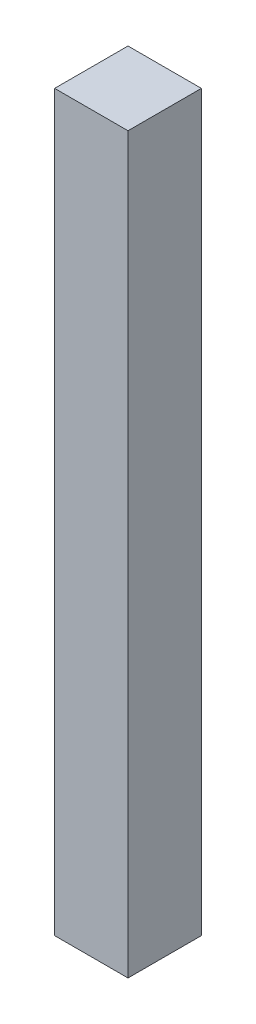
from build123d import *

# Parameters (mm, degrees)
SKETCH1_W           = 10
SKETCH1_H           = 100
BOSS_EXTRUDE1_DEPTH = 10


with BuildPart() as part:
    # Sketch1 → Boss-Extrude1 (new body)
    with BuildSketch(Plane.XY):
        Rectangle(SKETCH1_W, SKETCH1_H)
    extrude(amount=BOSS_EXTRUDE1_DEPTH)


solid = part.part
